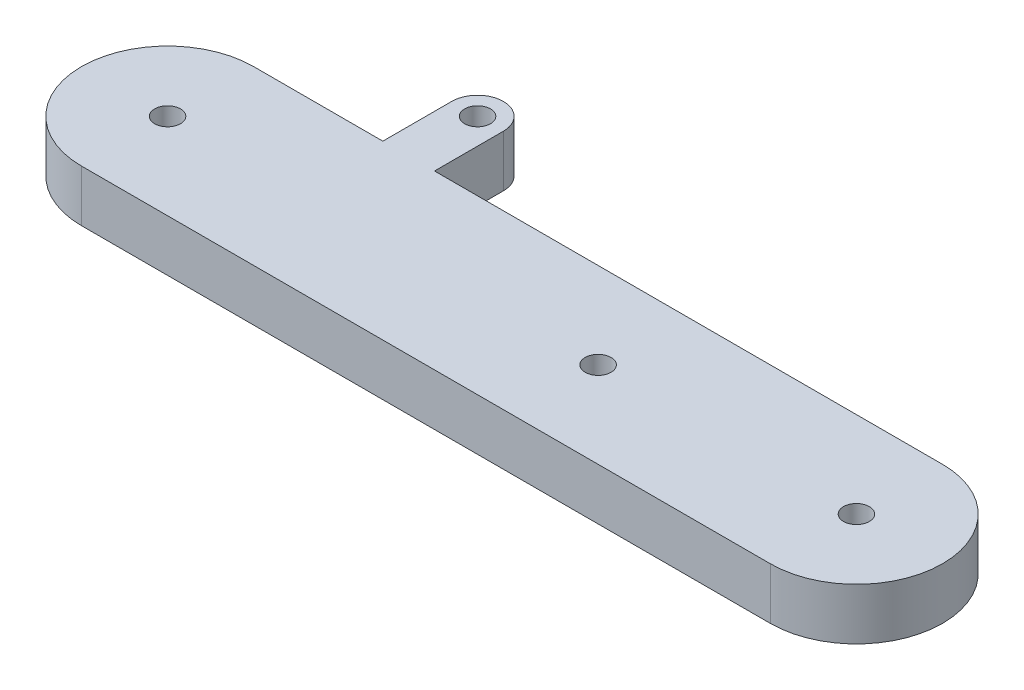
from build123d import *

# Parameters (mm, degrees)
SKETCH1_R           = 1.5
BOSS_EXTRUDE1_DEPTH = 6


with BuildPart() as part:
    # Sketch1 → Boss-Extrude1 (new body)
    with BuildSketch(Plane(origin=(0, 0, 0), x_dir=(1, 0, 0), z_dir=(0, 1, 0))):
        with BuildLine():
            Line((0, 0), (-80, 0))
            ThreePointArc((-80, 0), (-90, 10), (-80, 20))
            Line((-80, 20), (-65, 20))
            Line((-65, 20), (-65, 28))
            ThreePointArc((-65, 28), (-62, 31), (-59, 28))
            Line((-59, 28), (-59, 20))
            Line((-59, 20), (0, 20))
            ThreePointArc((0, 20), (10, 10), (0, 0))
        make_face()
        with Locations((-80, 10)):
            Circle(SKETCH1_R, mode=Mode.SUBTRACT)
        with Locations((0, 10)):
            Circle(SKETCH1_R, mode=Mode.SUBTRACT)
        with Locations((-30, 10)):
            Circle(SKETCH1_R, mode=Mode.SUBTRACT)
        with Locations((-62, 28)):
            Circle(SKETCH1_R, mode=Mode.SUBTRACT)
    extrude(amount=BOSS_EXTRUDE1_DEPTH)


solid = part.part
